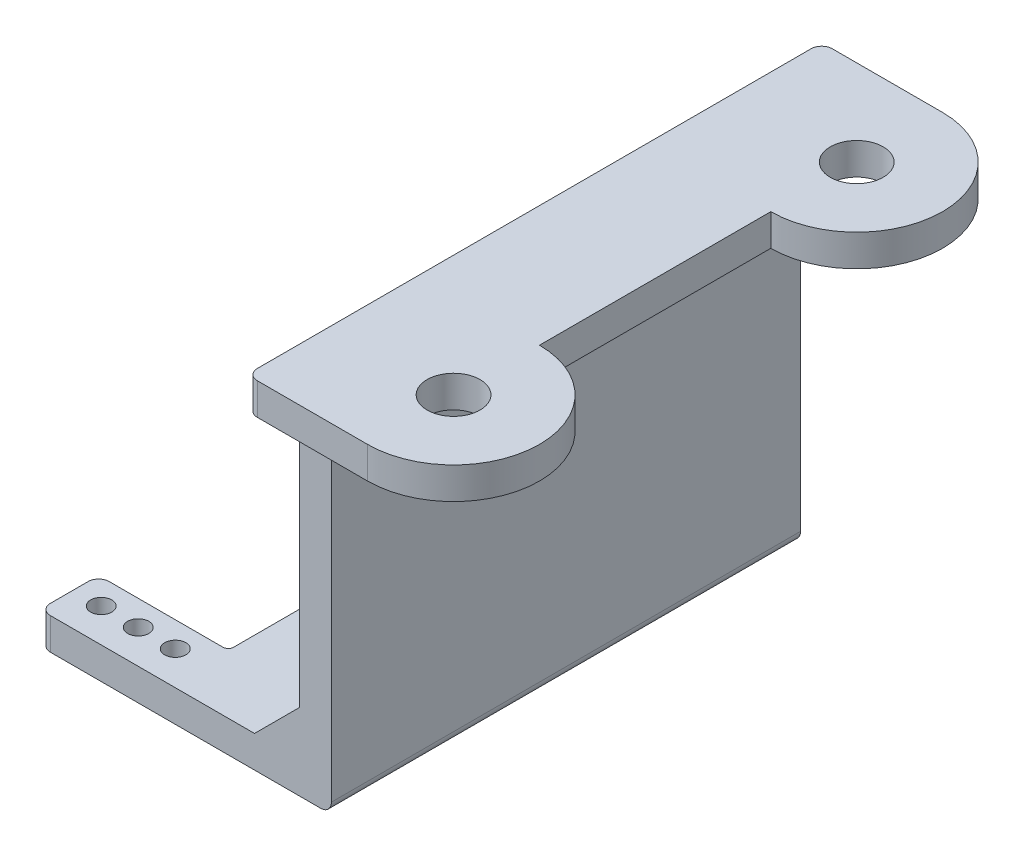
from build123d import *

# Parameters (mm, degrees)
SKETCH4_R           = 2.5
BOSS_EXTRUDE1_DEPTH = 3
SKETCH5_W           = 3
SKETCH5_H           = 44.34
BOSS_EXTRUDE2_DEPTH = 34
SKETCH11_R          = 1
BOSS_EXTRUDE3_DEPTH = 3
RIB7_REACH          = 99.577
SKETCH15_WALL_W     = 207.051776086
SKETCH15_WALL_H     = 2
LPATTERN2_COUNT     = 3
LPATTERN2_PITCH     = 4
LPATTERN2_COL_COUNT = 3
LPATTERN2_COL_PITCH = 4
RIB8_REACH          = 107.913
SKETCH16_WALL_W     = 219.851918098
SKETCH16_WALL_H     = 10
FILLET3_R           = 1
SKETCH17_W          = 24.34
SKETCH17_H          = 7
CUT_EXTRUDE1_DEPTH  = 2
FILLET4_R           = 0.5


with BuildPart() as part:
    # Sketch4 → Boss-Extrude1 (new body)
    with BuildSketch(Plane(origin=(0, 0, 0), x_dir=(1, 0, 0), z_dir=(0, 1, 0))):
        with BuildLine():
            Line((-61.549656869, 55.367306066), (-61.549656869, 1.027306066))
            Line((-61.549656869, 1.027306066), (-50.119656869, 1.027306066))
            ThreePointArc((-50.119656869, 1.027306066), (-41.999656869, 9.147306066), (-50.119656869, 17.267306066))
            Line((-50.119656869, 17.267306066), (-50.119656869, 39.127306066))
            ThreePointArc((-50.119656869, 39.127306066), (-41.999656869, 47.247306066), (-50.119656869, 55.367306066))
            Line((-50.119656869, 55.367306066), (-61.549656869, 55.367306066))
        make_face()
        with Locations(Location((-50.119656869, 47.247306066, 0), (0, 0, 270))):
            Circle(SKETCH4_R, mode=Mode.SUBTRACT)
        with Locations(Location((-50.119656869, 9.147306066, 0), (0, 0, 270))):
            Circle(SKETCH4_R, mode=Mode.SUBTRACT)
    extrude(amount=-BOSS_EXTRUDE1_DEPTH)

    # Sketch5 → Boss-Extrude2 (add)
    with BuildSketch(Plane.XZ.offset(3)):
        with Locations((-60.049656869, -28.197306066)):
            Rectangle(SKETCH5_W, SKETCH5_H)
    extrude(amount=BOSS_EXTRUDE2_DEPTH)

    # Sketch11 → Boss-Extrude3 (add)
    with BuildSketch(Plane.XZ.offset(37)):
        Polygon((-86.105180159, -35.362306066), (-86.105180159, -50.367306066), (-61.549656869, -50.367306066), (-61.549656869, -6.027306066), (-86.105180159, -6.027306066), (-86.105180159, -11.592306066), (-73.855180159, -11.592306066), (-73.855180159, -35.362306066), align=None)
        with Locations(Location((-83.485180159, -37.742306066, 0), (0, 0, 270))):
            Circle(SKETCH11_R, mode=Mode.SUBTRACT)
        with Locations(Location((-79.985180159, -37.742306066, 0), (0, 0, 270))):
            Circle(SKETCH11_R, mode=Mode.SUBTRACT)
        with Locations(Location((-76.485180159, -37.742306066, 0), (0, 0, 270))):
            Circle(SKETCH11_R, mode=Mode.SUBTRACT)
        with Locations(Location((-83.485180159, -9.212306066, 0), (0, 0, 270))):
            Circle(SKETCH11_R, mode=Mode.SUBTRACT)
        with Locations(Location((-79.985180159, -9.212306066, 0), (0, 0, 270))):
            Circle(SKETCH11_R, mode=Mode.SUBTRACT)
        with Locations(Location((-76.485180159, -9.212306066, 0), (0, 0, 270))):
            Circle(SKETCH11_R, mode=Mode.SUBTRACT)
    extrude(amount=-BOSS_EXTRUDE3_DEPTH)

    # Sketch15 wall → Rib7 (add, up to next)
    with BuildSketch(Plane(origin=(-54.334656869, -5.592920769, -28.197306066), x_dir=(0.851741772014, 0.523961786591, 0), z_dir=(-0.523961786591, 0.851741772014, 0)), mode=Mode.PRIVATE) as rib7_sk1:
        Rectangle(SKETCH15_WALL_W, SKETCH15_WALL_H)
    rib7_tool1 = extrude(rib7_sk1.sketch, amount=RIB7_REACH, mode=Mode.PRIVATE) - part.part
    rib7 = rib7_tool1.solids().sort_by_distance((-54.334656869, -5.592920769, -28.197306066))[0]
    add(rib7)

    # LPattern2: Rib7 ×3
    with Locations(*[(0, 0, -i * LPATTERN2_PITCH) for i in range(1, LPATTERN2_COUNT)]):
        add(rib7)

    # LPattern2 col: Rib7 ×3
    with Locations(*[(0, 0, i * LPATTERN2_COL_PITCH) for i in range(1, LPATTERN2_COL_COUNT)]):
        add(rib7)

    # Sketch16 wall → Rib8 (add, up to next)
    with BuildSketch(Plane(origin=(-63.680227165, -31.869429704, -6.027306066), x_dir=(0.707106781187, 0.707106781187, 0), z_dir=(-0.707106781187, 0.707106781187, 0)), mode=Mode.PRIVATE) as rib8_sk1:
        with Locations((0, 5)):
            Rectangle(SKETCH16_WALL_W, SKETCH16_WALL_H)
    rib8_tool1 = extrude(rib8_sk1.sketch, amount=-RIB8_REACH, mode=Mode.PRIVATE) - part.part
    rib8 = rib8_tool1.solids().sort_by_distance((-63.680227165, -31.869429704, -6.027306066))[0]
    add(rib8)

    # Mirror1: Rib8 across plane
    add(rib8.mirror(Plane.XY.offset(-28.197306066)))

    # Fillet3
    fillet3_edges = [part.edges().sort_by_distance(p)[0] for p in [
        (-61.549656869, -1.5, -1.027306066),
        (-61.549656869, -1.5, -55.367306066),
        (-60.049656869, -3, -50.367306066),
        (-60.049656869, -3, -6.027306066),
        (-58.549656869, -37, -28.197306066),
        (-86.105180159, -35.5, -11.592306066),
        (-86.105180159, -35.5, -6.027306066),
        (-86.105180159, -35.5, -50.367306066),
        (-86.105180159, -35.5, -35.362306066),
    ]]
    fillet(fillet3_edges, radius=FILLET3_R)

    # Sketch17 → Cut-Extrude1 (cut)
    with BuildSketch(Plane.ZY.offset(61.549656869)):
        with Locations((-28.197306066, -30.5)):
            Rectangle(SKETCH17_W, SKETCH17_H)
    extrude(amount=-CUT_EXTRUDE1_DEPTH, mode=Mode.SUBTRACT)

    # Fillet4
    fillet4_edges = [part.edges().sort_by_distance(p)[0] for p in [
        (-73.855180159, -35.5, -35.362306066),
        (-73.855180159, -35.5, -11.592306066),
    ]]
    fillet(fillet4_edges, radius=FILLET4_R)


solid = part.part
